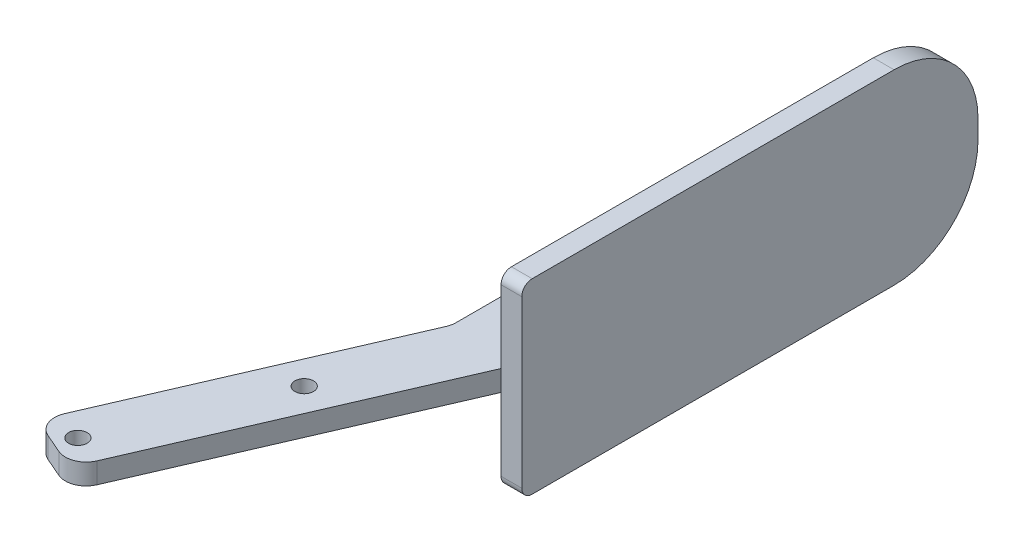
from build123d import *

# Parameters (mm, degrees)
SKETCH1_W           = 69.85
SKETCH1_H           = 28.575
BOSS_EXTRUDE1_DEPTH = 3.175
FILLET1_R           = 12.8524
BOSS_EXTRUDE2_DEPTH = 1.5875
FILLET2_R           = 1.5875
FILLET3_R           = 3.175
HOLE1_D             = 2.8448
LPATTERN1_COUNT     = 2
LPATTERN1_PITCH     = 26.3525


with BuildPart() as part:
    # Sketch1 → Boss-Extrude1 (new body)
    with BuildSketch(Plane(origin=(0, 0, 0), x_dir=(0, 0, -1), z_dir=(1, 0, 0))):
        with Locations((34.925, 0)):
            Rectangle(SKETCH1_W, SKETCH1_H)
    extrude(amount=BOSS_EXTRUDE1_DEPTH)

    # Fillet1
    fillet1_edges = [part.edges().sort_by_distance(p)[0] for p in [
        (1.5875, 14.2875, -69.85),
        (1.5875, -14.2875, -69.85),
    ]]
    fillet(fillet1_edges, radius=FILLET1_R)

    # Sketch4 → Boss-Extrude2 (add, symmetric)
    with BuildSketch(Plane(origin=(0, 0, 0), x_dir=(1, 0, 0), z_dir=(0, 1, 0))):
        Polygon((0, 0), (-19.950179226, -46.101), (-28.691757819, -42.318087272), (-9.525, 1.972577598), (-9.525, 55.499), (0, 55.499), align=None)
    extrude(amount=BOSS_EXTRUDE2_DEPTH, both=True)

    # Fillet2
    fillet2_edges = [part.edges().sort_by_distance(p)[0] for p in [
        (1.5875, -14.2875, 0),
        (1.5875, 14.2875, 0),
    ]]
    fillet(fillet2_edges, radius=FILLET2_R)

    # Fillet3
    fillet3_edges = [part.edges().sort_by_distance(p)[0] for p in [
        (-9.525, 0, -55.499),
        (-9.525, 0, -1.972577598),
        (-19.950179226, 0, 46.101),
        (-28.691757819, 0, 42.318087272),
    ]]
    fillet(fillet3_edges, radius=FILLET3_R)

    # Hole1 (through all)
    with Locations(Plane(origin=(0, 1.5875, 0), x_dir=(-1, 0, 0), z_dir=(0, 1, 0))):
        with Locations((23.191138588, 41.598725496)):
            hole1 = Hole(HOLE1_D / 2)

    # LPattern1: Hole1 ×2
    with Locations(*[Vector(0.397156192, 0, -0.917751033) * (i * LPATTERN1_PITCH) for i in range(1, LPATTERN1_COUNT)]):
        add(hole1, mode=Mode.SUBTRACT)


solid = part.part
